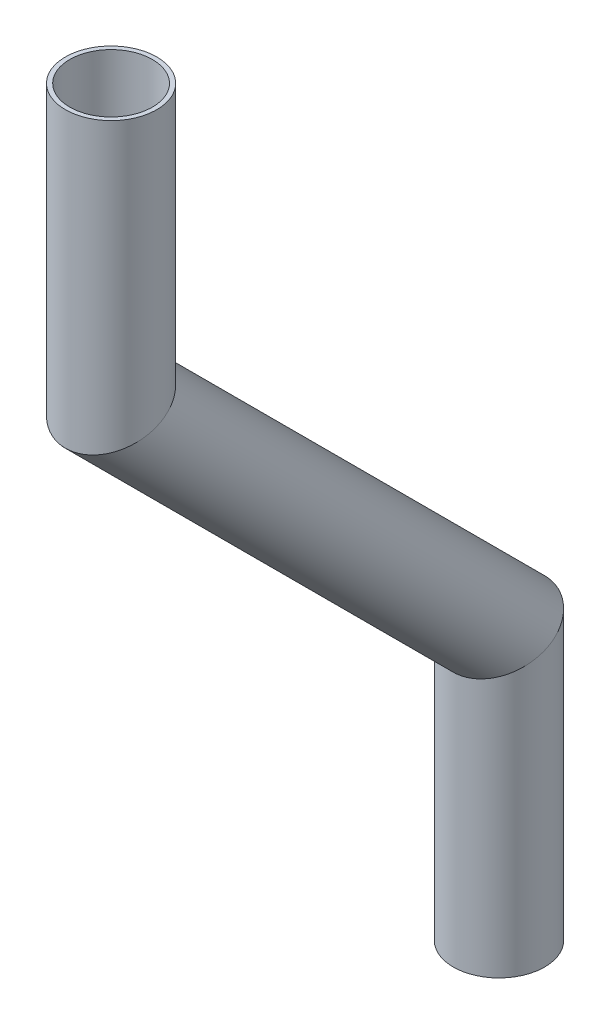
from build123d import *

# Parameters (mm, degrees)
SKETCH11_R                = 6.35
SKETCH11_R_2              = 5.7404
PIPE_0_5_SCH_40_1_DEPTH   = 42.819743879
SKETCH11_ON_SEGMENT_2_R   = 6.35
SKETCH11_ON_SEGMENT_2_R_2 = 5.7404
PIPE_0_5_SCH_40_1_2_DEPTH = 85.639487758
SKETCH11_ON_SEGMENT_3_R   = 6.35
SKETCH11_ON_SEGMENT_3_R_2 = 5.7404
PIPE_0_5_SCH_40_1_3_DEPTH = 42.819743879


with BuildPart() as part:
    # Sketch11 → Pipe 0.5 SCH 40(1) (new body)
    with BuildSketch(Plane(origin=(0, -54.917413554, 302.572169571), x_dir=(0, 0, -1), z_dir=(0, -1, 0))):
        Circle(SKETCH11_R)
        Circle(SKETCH11_R_2, mode=Mode.SUBTRACT)
    extrude(amount=PIPE_0_5_SCH_40_1_DEPTH)

    # Pipe 0.5 SCH 40(1) mitre 1
    split(bisect_by=Plane(origin=(0, -93.017413554, 302.572169571), x_dir=(-1, 0, 0), z_dir=(0, 0.923879533, 0.382683432)), keep=Keep.TOP)


with BuildPart() as body_2:
    # Sketch11 on segment 2 (carried to segment 2) → Pipe 0.5 SCH 40_1 2 (new body)
    with BuildSketch(Plane(origin=(0, -89.680050651, 305.909532473), x_dir=(0, 0.707106781, -0.707106781), z_dir=(0, -0.707106781, -0.707106781))):
        Circle(SKETCH11_ON_SEGMENT_2_R)
        Circle(SKETCH11_ON_SEGMENT_2_R_2, mode=Mode.SUBTRACT)
    extrude(amount=PIPE_0_5_SCH_40_1_2_DEPTH)

    # Pipe 0.5 SCH 40_1 2 mitre 1
    split(bisect_by=Plane(origin=(0, -93.017413554, 302.572169571), x_dir=(1, 0, 0), z_dir=(0, -0.923879533, -0.382683432)), keep=Keep.TOP)

    # Pipe 0.5 SCH 40_1 2 mitre 2
    split(bisect_by=Plane(origin=(0, -146.89895028, 248.690632844), x_dir=(-1, 0, 0), z_dir=(0, 0.923879533, 0.382683432)), keep=Keep.TOP)


with BuildPart() as body_3:
    # Sketch11 on segment 3 (carried to segment 3) → Pipe 0.5 SCH 40_1 3 (new body)
    with BuildSketch(Plane(origin=(0, -142.179206401, 248.690632844), x_dir=(0, 0, -1), z_dir=(0, -1, 0))):
        Circle(SKETCH11_ON_SEGMENT_3_R)
        Circle(SKETCH11_ON_SEGMENT_3_R_2, mode=Mode.SUBTRACT)
    extrude(amount=PIPE_0_5_SCH_40_1_3_DEPTH)

    # Pipe 0.5 SCH 40_1 3 mitre 1
    split(bisect_by=Plane(origin=(0, -146.89895028, 248.690632844), x_dir=(1, 0, 0), z_dir=(0, -0.923879533, -0.382683432)), keep=Keep.TOP)


solid = Compound([part.part, body_2.part, body_3.part])
